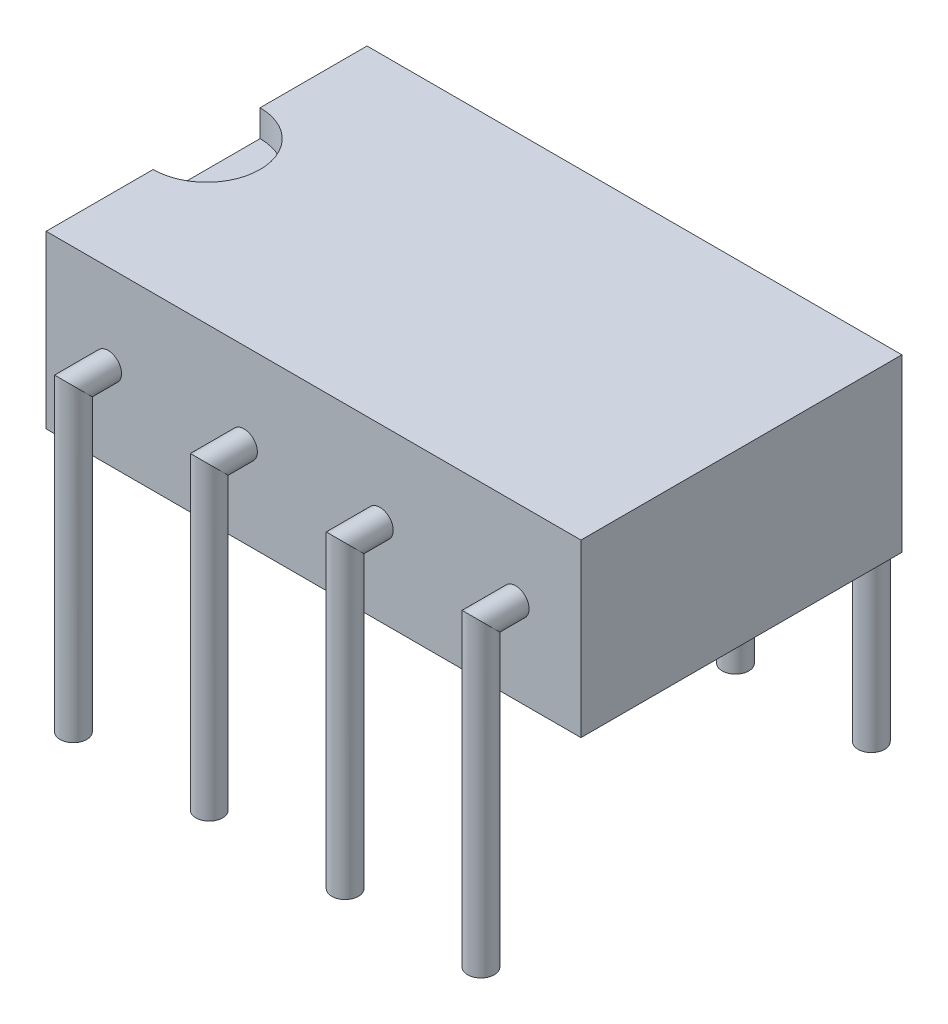
from build123d import *

# Parameters (mm, degrees)
ESQUISSE1_W                          = 6
ESQUISSE1_H                          = 3.2
EXTRUSION1_DEPTH                     = 10
ENL_V_MAT_EXTRU_1_DEPTH              = 0.5
ESQUISSE3_R                          = 0.25
R_P_TITION_LIN_AIRE1_COUNT           = 4
R_P_TITION_LIN_AIRE1_PITCH           = 2.54
R_P_TITION_LIN_AIRE1_COPY_1_SKETCH_R = 0.25
R_P_TITION_LIN_AIRE1_COPY_2_SKETCH_R = 0.25
R_P_TITION_LIN_AIRE1_COPY_3_SKETCH_R = 0.25


with BuildPart() as part:
    # Esquisse1 → Extrusion1 (new body)
    with BuildSketch(Plane(origin=(0, 0, 0), x_dir=(0, 0, -1), z_dir=(1, 0, 0))):
        with Locations((0, 1.6)):
            Rectangle(ESQUISSE1_W, ESQUISSE1_H)
    extrude(amount=EXTRUSION1_DEPTH)

    # Esquisse2 → Enlèv. mat.-Extru.1 (cut)
    with BuildSketch(Plane(origin=(0, 3.2, 0), x_dir=(-1, 0, 0), z_dir=(0, 1, 0))):
        with BuildLine():
            Line((0, -1), (0, 1))
            ThreePointArc((0, 1), (-1, 0), (0, -1))
        make_face()
    extrude(amount=-ENL_V_MAT_EXTRU_1_DEPTH, mode=Mode.SUBTRACT)

    # Balayage1: sweep along a path in Esquisse5
    with BuildLine(Plane(origin=(1.16, 0, 0), x_dir=(0, 0, -1), z_dir=(1, 0, 0))) as balayage1_path:
        Line((-3, 1.6), (-3.65, 1.6))
        Line((-3.65, 1.6), (-3.65, -4))
    # Esquisse3 → Balayage1 (sweep)
    with BuildSketch(Plane.XY.offset(3)):
        with Locations((1.16, 1.6)):
            Circle(ESQUISSE3_R)
    balayage1 = sweep(path=balayage1_path.line, transition=Transition.RIGHT)

    # Symétrie1: Balayage1 across plane
    add(balayage1.mirror(Plane.XY))

    # Répétition linéaire1: Balayage1 ×4
    with Locations(*[(i * R_P_TITION_LIN_AIRE1_PITCH, 0, 0) for i in range(1, R_P_TITION_LIN_AIRE1_COUNT)]):
        add(balayage1)

    # Répétition linéaire1 copy 1: sweep along a path in Répétition linéaire1 copy 1 path
    with BuildLine(Plane(origin=(3.7, 0, 0), x_dir=(0, 0, 1), z_dir=(1, 0, 0))) as r_p_tition_lin_aire1_copy_1_path:
        Line((-3, -1.6), (-3.65, -1.6))
        Line((-3.65, -1.6), (-3.65, 4))
    # Répétition linéaire1 copy 1 sketch → Répétition linéaire1 copy 1 (sweep)
    with BuildSketch(Plane(origin=(2.54, 0, -3), x_dir=(1, 0, 0), z_dir=(0, 0, -1))):
        with Locations((1.16, -1.6)):
            Circle(R_P_TITION_LIN_AIRE1_COPY_1_SKETCH_R)
    sweep(path=r_p_tition_lin_aire1_copy_1_path.line, transition=Transition.RIGHT)

    # Répétition linéaire1 copy 2: sweep along a path in Répétition linéaire1 copy 2 path
    with BuildLine(Plane(origin=(6.24, 0, 0), x_dir=(0, 0, 1), z_dir=(1, 0, 0))) as r_p_tition_lin_aire1_copy_2_path:
        Line((-3, -1.6), (-3.65, -1.6))
        Line((-3.65, -1.6), (-3.65, 4))
    # Répétition linéaire1 copy 2 sketch → Répétition linéaire1 copy 2 (sweep)
    with BuildSketch(Plane(origin=(5.08, 0, -3), x_dir=(1, 0, 0), z_dir=(0, 0, -1))):
        with Locations((1.16, -1.6)):
            Circle(R_P_TITION_LIN_AIRE1_COPY_2_SKETCH_R)
    sweep(path=r_p_tition_lin_aire1_copy_2_path.line, transition=Transition.RIGHT)

    # Répétition linéaire1 copy 3: sweep along a path in Répétition linéaire1 copy 3 path
    with BuildLine(Plane(origin=(8.78, 0, 0), x_dir=(0, 0, 1), z_dir=(1, 0, 0))) as r_p_tition_lin_aire1_copy_3_path:
        Line((-3, -1.6), (-3.65, -1.6))
        Line((-3.65, -1.6), (-3.65, 4))
    # Répétition linéaire1 copy 3 sketch → Répétition linéaire1 copy 3 (sweep)
    with BuildSketch(Plane(origin=(7.62, 0, -3), x_dir=(1, 0, 0), z_dir=(0, 0, -1))):
        with Locations((1.16, -1.6)):
            Circle(R_P_TITION_LIN_AIRE1_COPY_3_SKETCH_R)
    sweep(path=r_p_tition_lin_aire1_copy_3_path.line, transition=Transition.RIGHT)


solid = part.part
